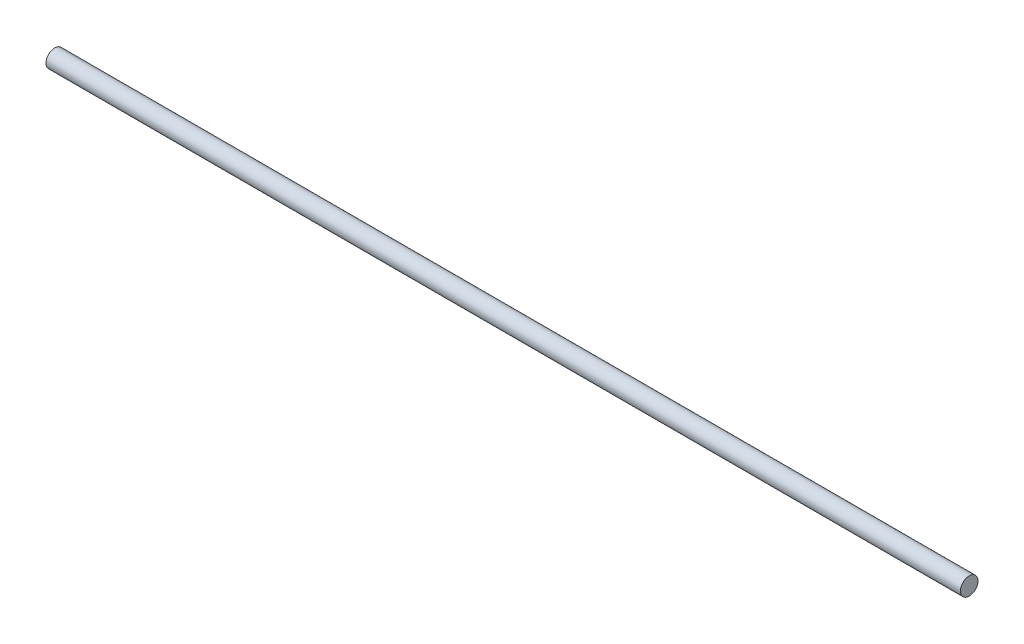
from build123d import *

# Parameters (mm, degrees)
SKETCH1_R           = 6.35
BOSS_EXTRUDE1_DEPTH = 330.2


with BuildPart() as part:
    # Sketch1 → Boss-Extrude1 (new body, symmetric)
    with BuildSketch(Plane(origin=(0, 0, 0), x_dir=(0, 0, -1), z_dir=(1, 0, 0))):
        Circle(SKETCH1_R)
    extrude(amount=BOSS_EXTRUDE1_DEPTH, both=True)


solid = part.part
